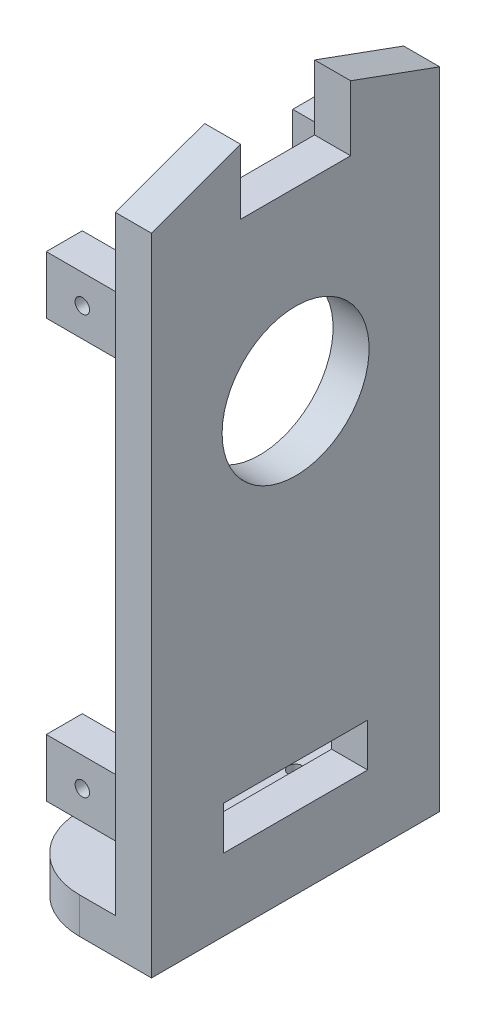
from build123d import *

# Parameters (mm, degrees)
SKETCH1_R           = 1
BOSS_EXTRUDE1_DEPTH = 5
SKETCH2_W           = 5
SKETCH2_H           = 40
BOSS_EXTRUDE2_DEPTH = 80
SKETCH3_R           = 2.22
CUT_EXTRUDE3_DEPTH  = 80
BOSS_EXTRUDE5_DEPTH = 5
SKETCH9_W           = 20
SKETCH9_H           = 6
CUT_EXTRUDE7_DEPTH  = 10
SKETCH10_W          = 5
SKETCH10_H          = 8
BOSS_EXTRUDE6_DEPTH = 10
SKETCH11_R          = 1
CUT_EXTRUDE9_DEPTH  = 8
SKETCH12_R          = 1
CUT_EXTRUDE10_DEPTH = 8
SKETCH5_R           = 2.22
BOSS_EXTRUDE7_DEPTH = 5
SKETCH14_R          = 10.2
BOSS_EXTRUDE8_DEPTH = 5


with BuildPart() as part:
    # Sketch1 → Boss-Extrude1 (new body)
    with BuildSketch(Plane(origin=(0, 0, 0), x_dir=(1, 0, 0), z_dir=(0, 1, 0))):
        with BuildLine():
            Line((5.319641756, -11.332905968), (15.319641756, -11.332905968))
            Line((15.319641756, -11.332905968), (15.319641756, 28.667094032))
            Line((15.319641756, 28.667094032), (5.319641756, 28.667094032))
            ThreePointArc((5.319641756, 28.667094032), (-1.751426056, 25.738161844), (-4.680358244, 18.667094032))
            Line((-4.680358244, 18.667094032), (-4.680358244, -1.332905968))
            ThreePointArc((-4.680358244, -1.332905968), (-1.751426056, -8.40397378), (5.319641756, -11.332905968))
        make_face()
        with Locations((5.319641756, 18.667094032)):
            Circle(SKETCH1_R, mode=Mode.SUBTRACT)
        with Locations((5.319641756, -1.332905968)):
            Circle(SKETCH1_R, mode=Mode.SUBTRACT)
    extrude(amount=BOSS_EXTRUDE1_DEPTH)

    # Sketch2 → Boss-Extrude2 (add)
    with BuildSketch(Plane(origin=(0, 5, 0), x_dir=(1, 0, 0), z_dir=(0, 1, 0))):
        with Locations((12.819641756, 8.667094032)):
            Rectangle(SKETCH2_W, SKETCH2_H)
    extrude(amount=BOSS_EXTRUDE2_DEPTH)

    # Sketch3 → Cut-Extrude3 (cut)
    with BuildSketch(Plane.ZY.offset(-10.319641756)):
        with BuildLine():
            ThreePointArc((0.732905968, 35.401978793), (1.440012749, 35.694872012), (1.732905968, 36.401978793))
            Line((1.732905968, 36.401978793), (1.732905968, 69.94419701))
            ThreePointArc((1.732905968, 69.94419701), (1.440012749, 70.651303792), (0.732905968, 70.94419701))
            Line((0.732905968, 70.94419701), (-18.067094032, 70.94419701))
            ThreePointArc((-18.067094032, 70.94419701), (-18.774200813, 70.651303792), (-19.067094032, 69.94419701))
            Line((-19.067094032, 69.94419701), (-19.067094032, 36.401978793))
            ThreePointArc((-19.067094032, 36.401978793), (-18.774200813, 35.694872012), (-18.067094032, 35.401978793))
            Line((-18.067094032, 35.401978793), (0.732905968, 35.401978793))
        make_face()
        with Locations((-13.167094032, 75.54419701)):
            Circle(SKETCH3_R)
        with Locations((-13.167094032, 25.24419701)):
            Circle(SKETCH3_R)
        with Locations((-4.167094032, 25.24419701)):
            Circle(SKETCH3_R)
        with Locations((-4.167094032, 75.54419701)):
            Circle(SKETCH3_R)
    extrude(amount=-CUT_EXTRUDE3_DEPTH, mode=Mode.SUBTRACT)

    # Sketch8 → Boss-Extrude5 (add, through all)
    with BuildSketch(Plane.ZY.offset(-10.319641756)):
        Polygon((-28.667094032, 89.50779106), (-28.667094032, 85), (-16.300533883, 85), (-16.300533883, 94.015582119), align=None)
        Polygon((-1.033654181, 94.015582119), (-1.033654181, 85), (11.332905968, 85), (11.332905968, 89.50779106), align=None)
    extrude(amount=-BOSS_EXTRUDE5_DEPTH)

    # Sketch9 → Cut-Extrude7 (cut)
    with BuildSketch(Plane.ZY.offset(-10.319641756)):
        with Locations((-8.667094032, 13)):
            Rectangle(SKETCH9_W, SKETCH9_H)
    extrude(amount=-CUT_EXTRUDE7_DEPTH, mode=Mode.SUBTRACT)

    # Sketch10 → Boss-Extrude6 (add)
    with BuildSketch(Plane.ZY.offset(-10.319641756)):
        with Locations((-25.767094032, 17.566871705)):
            Rectangle(SKETCH10_W, SKETCH10_H)
        with Locations((8.432905968, 17.566871705)):
            Rectangle(SKETCH10_W, SKETCH10_H)
        with Locations((8.432905968, 75.6)):
            Rectangle(SKETCH10_W, SKETCH10_H)
        with Locations((-25.767094032, 75.6)):
            Rectangle(SKETCH10_W, SKETCH10_H)
    extrude(amount=BOSS_EXTRUDE6_DEPTH)

    # Sketch11 → Cut-Extrude9 (cut)
    with BuildSketch(Plane.XY.offset(10.932905968)):
        with Locations((5.319641756, 17.566871705)):
            Circle(SKETCH11_R)
        with Locations((5.319641756, 75.6)):
            Circle(SKETCH11_R)
    extrude(amount=-CUT_EXTRUDE9_DEPTH, mode=Mode.SUBTRACT)

    # Sketch12 → Cut-Extrude10 (cut)
    with BuildSketch(Plane(origin=(0, 0, -28.267094032), x_dir=(-1, 0, 0), z_dir=(0, 0, -1))):
        with Locations((-5.319641756, 75.6)):
            Circle(SKETCH12_R)
        with Locations((-5.319641756, 17.566871705)):
            Circle(SKETCH12_R)
    extrude(amount=-CUT_EXTRUDE10_DEPTH, mode=Mode.SUBTRACT)

    # Sketch5 → Boss-Extrude7 (add)
    with BuildSketch(Plane(origin=(15.319641756, 0, 0), x_dir=(0, 0, -1), z_dir=(1, 0, 0))):
        with Locations((4.167094032, 25.24419701)):
            Circle(SKETCH5_R)
        with Locations((13.167094032, 25.24419701)):
            Circle(SKETCH5_R)
        with Locations((4.167094032, 75.54419701)):
            Circle(SKETCH5_R)
        with Locations((13.167094032, 75.54419701)):
            Circle(SKETCH5_R)
    extrude(amount=-BOSS_EXTRUDE7_DEPTH)

    # Sketch14 → Boss-Extrude8 (add)
    with BuildSketch(Plane.ZY.offset(-10.319641756)):
        with BuildLine():
            Line((0.732905968, 70.94419701), (-18.067094032, 70.94419701))
            ThreePointArc((-18.067094032, 70.94419701), (-18.774200813, 70.651303792), (-19.067094032, 69.94419701))
            Line((-19.067094032, 69.94419701), (-19.067094032, 36.401978793))
            ThreePointArc((-19.067094032, 36.401978793), (-18.774200813, 35.694872012), (-18.067094032, 35.401978793))
            Line((-18.067094032, 35.401978793), (0.732905968, 35.401978793))
            ThreePointArc((0.732905968, 35.401978793), (1.440012749, 35.694872012), (1.732905968, 36.401978793))
            Line((1.732905968, 36.401978793), (1.732905968, 69.94419701))
            ThreePointArc((1.732905968, 69.94419701), (1.440012749, 70.651303792), (0.732905968, 70.94419701))
        make_face()
        with Locations((-8.667094032, 60.54)):
            Circle(SKETCH14_R, mode=Mode.SUBTRACT)
    extrude(amount=-BOSS_EXTRUDE8_DEPTH)


solid = part.part
